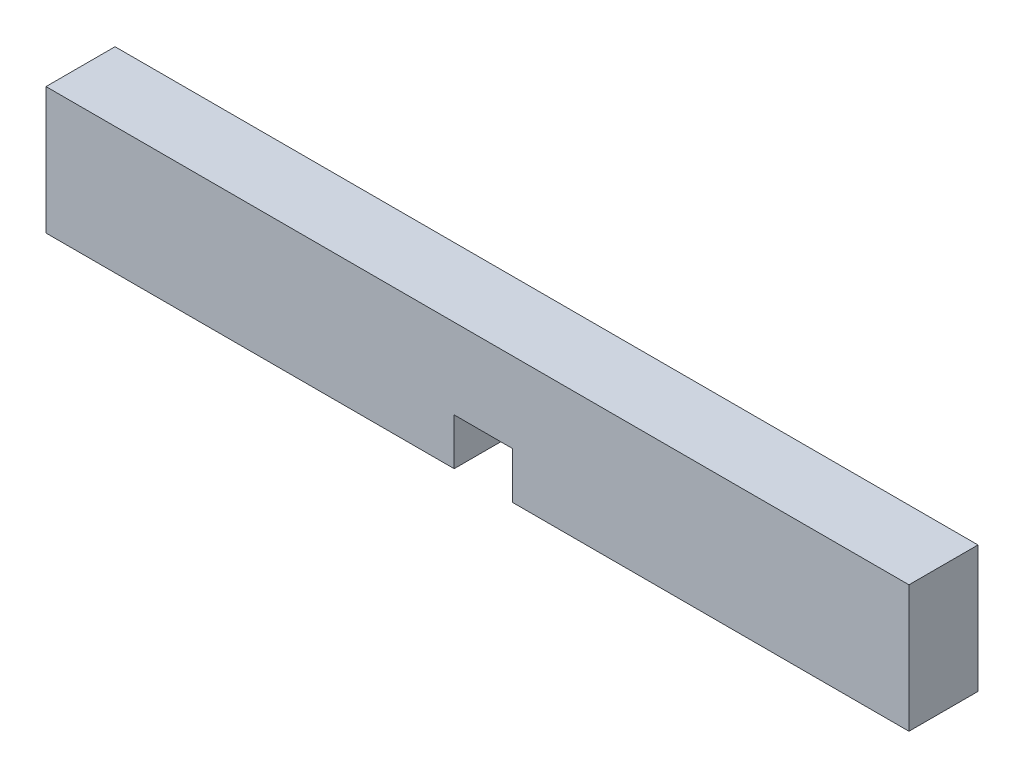
from build123d import *

# Parameters (mm, degrees)
SKETCH1_W          = 58.7375
SKETCH1_H          = 8.636
EXTRUDE1_DEPTH     = 4.699
SKETCH3_W          = 3.96875
SKETCH3_H          = 3.175
CUT_EXTRUDE1_DEPTH = 5.699


with BuildPart() as part:
    # Sketch1 → Extrude1 (new body)
    with BuildSketch(Plane.XY):
        with Locations((29.36875, 4.318)):
            Rectangle(SKETCH1_W, SKETCH1_H)
    extrude(amount=EXTRUDE1_DEPTH)

    # Sketch3 → Cut-Extrude1 (cut, through all)
    with BuildSketch(Plane.XY.offset(4.699)):
        with Locations((29.765625, 1.5875)):
            Rectangle(SKETCH3_W, SKETCH3_H)
    extrude(amount=-CUT_EXTRUDE1_DEPTH, mode=Mode.SUBTRACT)


solid = part.part
